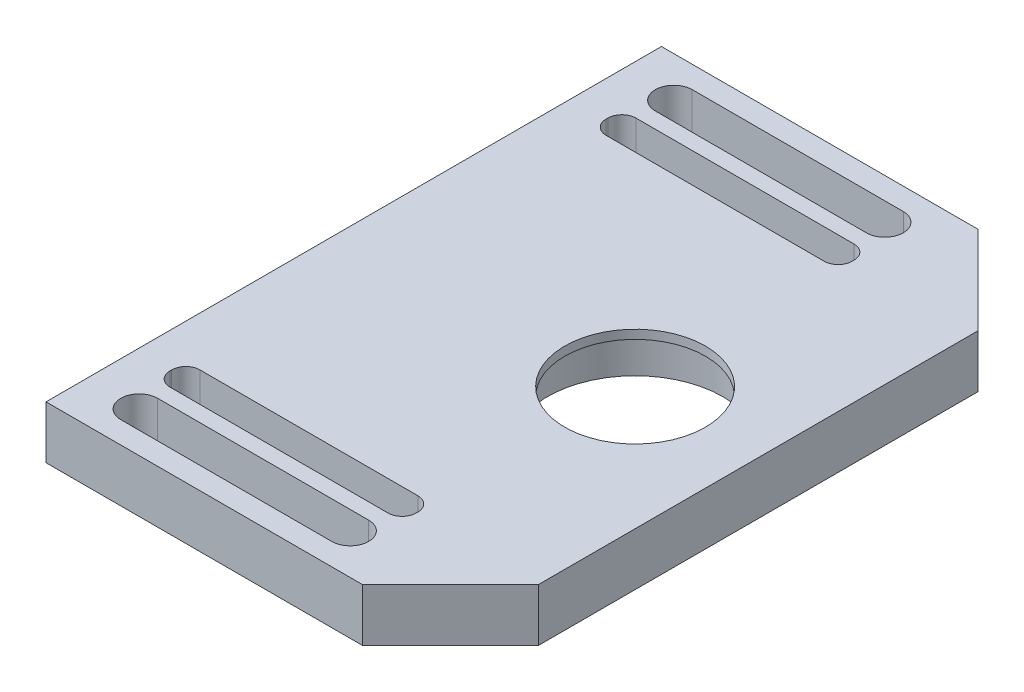
from build123d import *

# Parameters (mm, degrees)
SKIZZE1_W                       = 14
SKIZZE1_H                       = 1.7
AUFSATZ_LINEAR_AUSTRAGEN1_DEPTH = 1.5
VERRUNDUNG1_R                   = 0.8
SKIZZE4_R                       = 5
SCHNITT_LINEAR_AUSTRAGEN1_DEPTH = 2.5
SKIZZE4_3_R                     = 4
SCHNITT_LINEAR_AUSTRAGEN2_DEPTH = 4


with BuildPart() as part:
    # Skizze1 → Aufsatz-Linear austragen1 (new body, symmetric)
    with BuildSketch(Plane(origin=(0, 0, 0), x_dir=(1, 0, 0), z_dir=(0, 1, 0))):
        Polygon((-9, 17.5), (9, 17.5), (14, 12.5), (14, -12.5), (9, -17.5), (-9, -17.5), align=None)
        with BuildLine():
            Line((-6, -16.25), (6, -16.25))
            ThreePointArc((6, -16.25), (7.05, -15.2), (6, -14.15))
            Line((6, -14.15), (-6, -14.15))
            ThreePointArc((-6, -14.15), (-7.05, -15.2), (-6, -16.25))
        make_face(mode=Mode.SUBTRACT)
        with Locations((0, 12.4)):
            Rectangle(SKIZZE1_W, SKIZZE1_H, mode=Mode.SUBTRACT)
        with BuildLine():
            Line((-6, 16.25), (6, 16.25))
            ThreePointArc((6, 16.25), (7.05, 15.2), (6, 14.15))
            Line((6, 14.15), (-6, 14.15))
            ThreePointArc((-6, 14.15), (-7.05, 15.2), (-6, 16.25))
        make_face(mode=Mode.SUBTRACT)
        with Locations((0, -12.4)):
            Rectangle(SKIZZE1_W, SKIZZE1_H, mode=Mode.SUBTRACT)
    extrude(amount=AUFSATZ_LINEAR_AUSTRAGEN1_DEPTH, both=True)

    # Verrundung1
    verrundung1_edges = [part.edges().sort_by_distance(p)[0] for p in [
        (-7, 0, -11.55),
        (-7, 0, -13.25),
        (7, 0, -13.25),
        (7, 0, -11.55),
        (7, 0, 13.25),
        (-7, 0, 13.25),
        (-7, 0, 11.55),
        (7, 0, 11.55),
    ]]
    fillet(verrundung1_edges, radius=VERRUNDUNG1_R)

    # Skizze4 → Schnitt-Linear austragen1 (cut)
    with BuildSketch(Plane.XZ.offset(1.5)):
        with Locations((7, 0)):
            Circle(SKIZZE4_R)
    extrude(amount=-SCHNITT_LINEAR_AUSTRAGEN1_DEPTH, mode=Mode.SUBTRACT)

    # Skizze4_3 → Schnitt-Linear austragen2 (cut, through all)
    with BuildSketch(Plane.XZ.offset(1.5)):
        with Locations((7, 0)):
            Circle(SKIZZE4_3_R)
    extrude(amount=-SCHNITT_LINEAR_AUSTRAGEN2_DEPTH, mode=Mode.SUBTRACT)


solid = part.part
